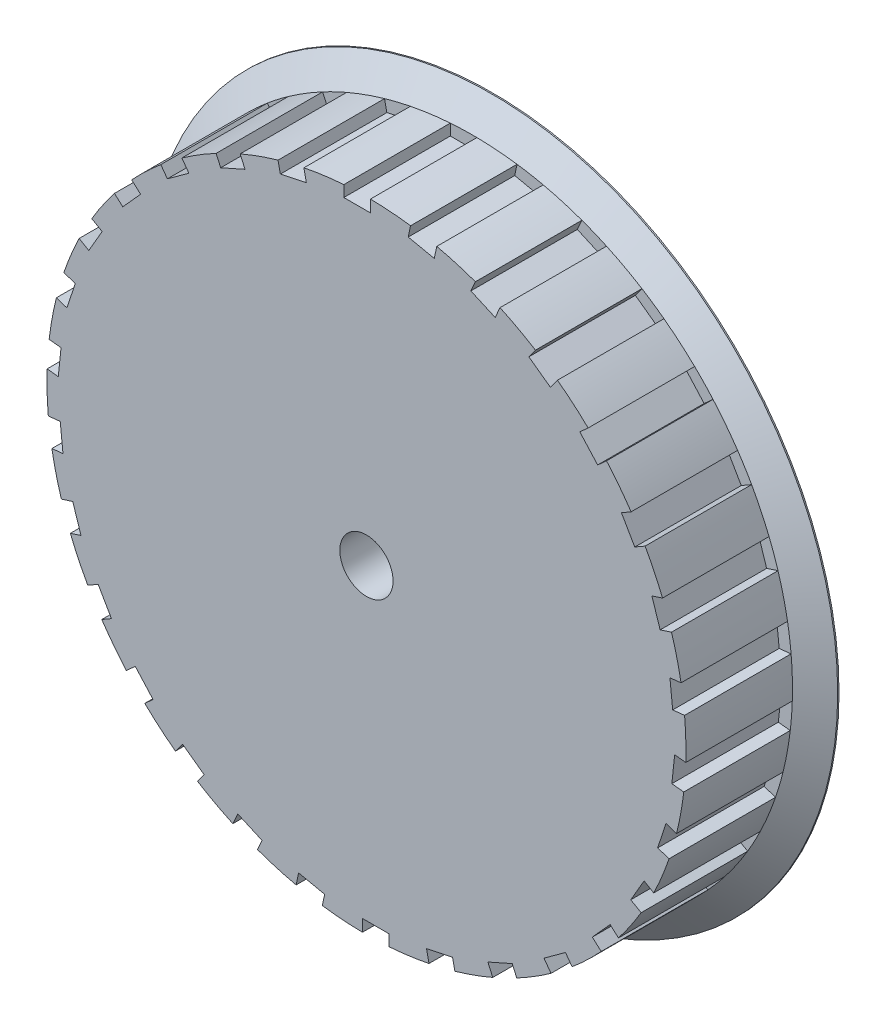
from build123d import *

# Parameters (mm, degrees)
SKETCH2_R          = 2
CUT_EXTRUDE1_DEPTH = 34
SKETCH3_W          = 2
SKETCH3_H          = 3.810210747
CUT_EXTRUDE2_DEPTH = 4
CIRPATTERN1_COUNT  = 30
SKETCH4_R          = 35.761747599
CUT_EXTRUDE3_DEPTH = 1.5


with BuildPart() as part:
    # Sketch1 → Revolve1 (revolve)
    with BuildSketch(Plane(origin=(0, 0, 0), x_dir=(0, 0, -1), z_dir=(1, 0, 0))):
        Polygon((-5.5, 0), (-5.5, 26), (-5.400415076, 26), (-4, 24), (0, 24), (0, 0), align=None)
    revolve1 = revolve(axis=Axis((0, 0, 5.5), (0, 0, -1)))

    # Mirror1: Revolve1 across plane
    add(revolve1.mirror(Plane.XY))

    # Sketch2 → Cut-Extrude1 (cut)
    with BuildSketch(Plane.XY.offset(5.5)):
        Circle(SKETCH2_R)
    extrude(amount=-CUT_EXTRUDE1_DEPTH, mode=Mode.SUBTRACT)

    # Sketch3 → Cut-Extrude2 (cut, symmetric)
    with BuildSketch(Plane.XY):
        with Locations((-0.70098694, 25.004508025)):
            Rectangle(SKETCH3_W, SKETCH3_H)
    cut_extrude2 = extrude(amount=CUT_EXTRUDE2_DEPTH, both=True, mode=Mode.SUBTRACT)

    # CirPattern1: Cut-Extrude2 ×30 about axis
    cirpattern1_axis = Axis((0, 0, 0), (0, 0, 1))
    for i in range(1, CIRPATTERN1_COUNT):
        add(cut_extrude2.rotate(cirpattern1_axis, i * 360 / CIRPATTERN1_COUNT), mode=Mode.SUBTRACT)

    # Sketch4 → Cut-Extrude3 (cut)
    with BuildSketch(Plane.XY.offset(5.5)):
        Circle(SKETCH4_R)
    extrude(amount=-CUT_EXTRUDE3_DEPTH, mode=Mode.SUBTRACT)


solid = part.part
